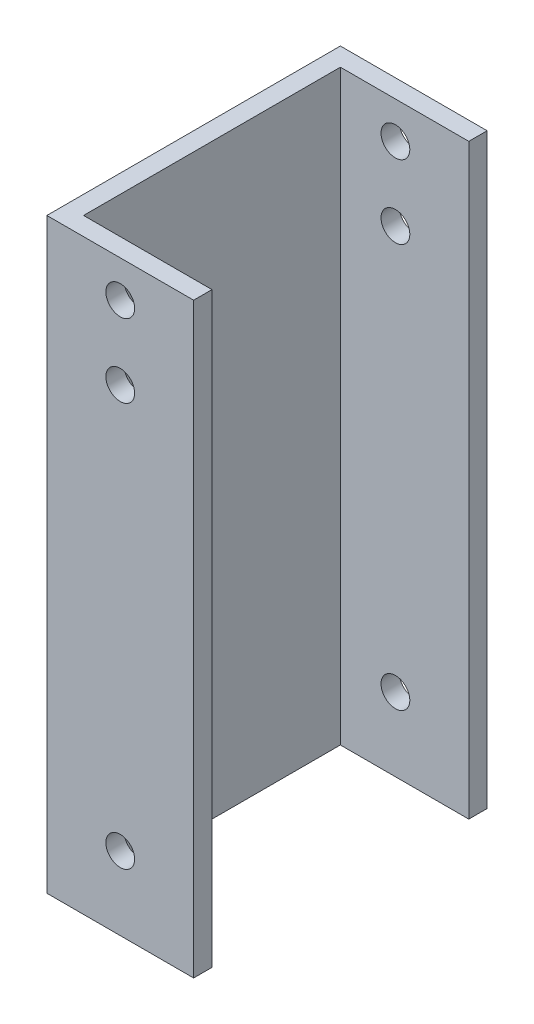
from build123d import *

# Parameters (mm, degrees)
BOSS_EXTRUDE1_DEPTH = 101.6
SKETCH2_R           = 2.4892
CUT_EXTRUDE1_DEPTH  = 51.8


with BuildPart() as part:
    # Sketch1 → Boss-Extrude1 (new body)
    with BuildSketch(Plane(origin=(0, 0, 0), x_dir=(1, 0, 0), z_dir=(0, 1, 0))):
        Polygon((0, 0), (25.4, 0), (25.4, 3.175), (3.175, 3.175), (3.175, 47.625), (25.4, 47.625), (25.4, 50.8), (0, 50.8), align=None)
    extrude(amount=BOSS_EXTRUDE1_DEPTH)

    # Sketch2 → Cut-Extrude1 (cut, through all)
    with BuildSketch(Plane(origin=(0, 0, -50.8), x_dir=(-1, 0, 0), z_dir=(0, 0, -1))):
        with Locations((-12.7, 12.7)):
            Circle(SKETCH2_R)
        with Locations((-12.7, 95.25)):
            Circle(SKETCH2_R)
        with Locations((-12.7, 82.55)):
            Circle(SKETCH2_R)
    extrude(amount=-CUT_EXTRUDE1_DEPTH, mode=Mode.SUBTRACT)


solid = part.part
